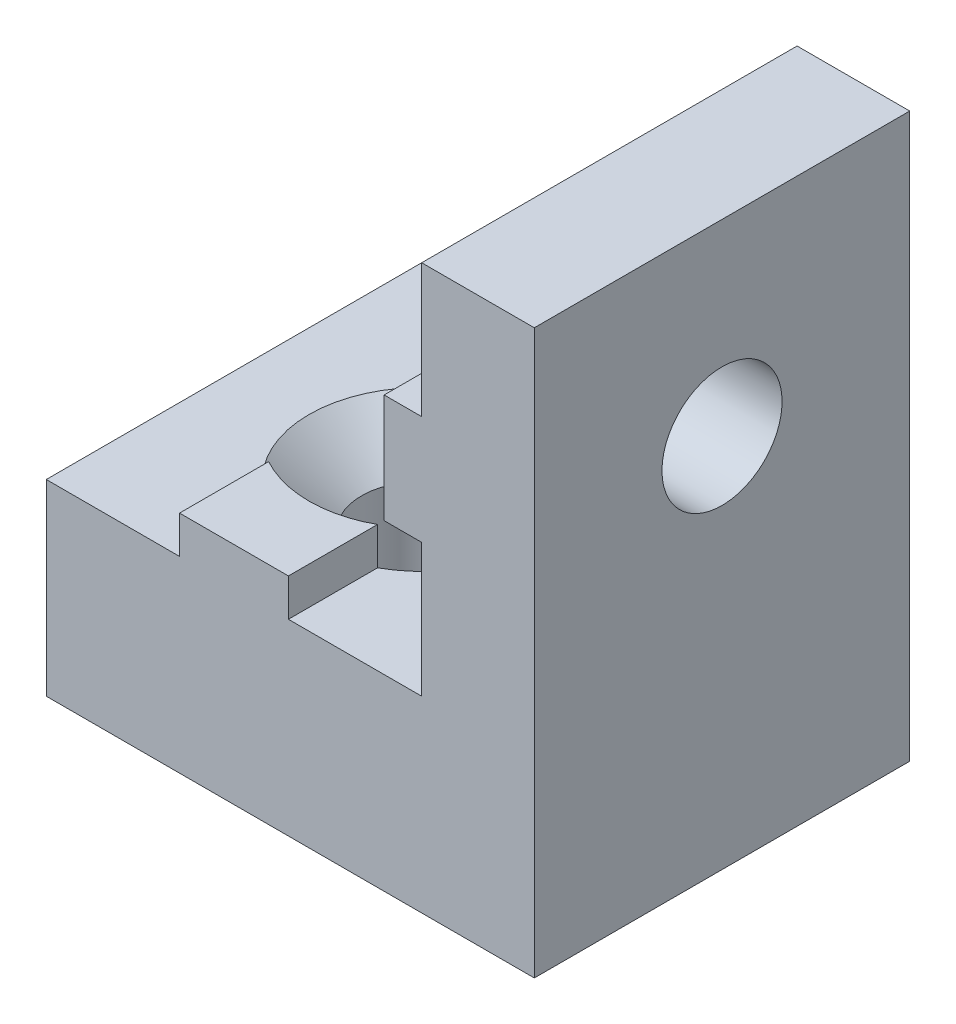
from build123d import *

# Parameters (mm, degrees)
MAIN_DEPTH              = 10
ESQUISSE5_R             = 3
ENL_V_MAT_EXTRU_1_DEPTH = 1
ESQUISSE6_R             = 1.6
ENL_V_MAT_EXTRU_2_DEPTH = 5


with BuildPart() as part:
    # Esquisse1 → Main (new body)
    with BuildSketch(Plane.XY):
        Polygon((0, 5), (3.55, 5), (3.55, 6), (6.45, 6), (6.45, 5), (10, 5), (10, 8.55), (9, 8.55), (9, 11.45), (10, 11.45), (10, 15), (13, 15), (13, 0), (0, 0), align=None)
    extrude(amount=MAIN_DEPTH)

    # Esquisse4 → Fraisage pour vis à tête fraisée (100) #01 (revolve, cut)
    with BuildSketch(Plane(origin=(5, 5, 5), x_dir=(0, 0, 1), z_dir=(1, 0, 0))):
        Polygon((0, 0), (0, 5), (1.6, 5), (1.6, 1.174739484), (3, 0), align=None)
    revolve(axis=Axis((5, 11.35, 5), (0, -1, 0)), mode=Mode.SUBTRACT)

    # Esquisse5 → Enlèv. mat.-Extru.1 (cut)
    with BuildSketch(Plane(origin=(0, 6, 0), x_dir=(1, 0, 0), z_dir=(0, 1, 0))):
        with Locations((5, -5)):
            Circle(ESQUISSE5_R)
    extrude(amount=-ENL_V_MAT_EXTRU_1_DEPTH, mode=Mode.SUBTRACT)

    # Esquisse6 → Enlèv. mat.-Extru.2 (cut, through all)
    with BuildSketch(Plane.ZY.offset(-9)):
        with Locations((5, 10)):
            Circle(ESQUISSE6_R)
    extrude(amount=-ENL_V_MAT_EXTRU_2_DEPTH, mode=Mode.SUBTRACT)


solid = part.part
